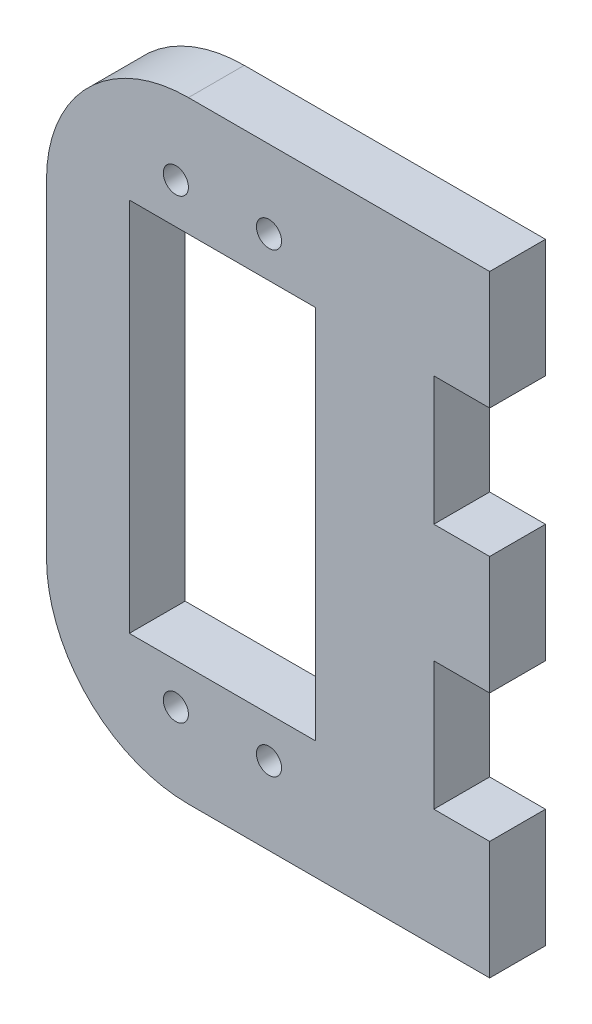
from build123d import *

# Parameters (mm, degrees)
SKETCH1_R           = 1.35
SKETCH1_W           = 20
SKETCH1_H           = 40.3
BOSS_EXTRUDE1_DEPTH = 5.9944


with BuildPart() as part:
    # Sketch1 → Boss-Extrude1 (new body)
    with BuildSketch(Plane.XY):
        with BuildLine():
            ThreePointArc((-18.89, 17.61), (-14.426307345, 28.386307345), (-3.65, 32.85))
            Line((-3.65, 32.85), (10, 32.85))
            Line((10, 32.85), (22.7, 32.85))
            Line((22.7, 32.85), (28.6944, 32.85))
            Line((28.6944, 32.85), (28.6944, 20.15))
            Line((28.6944, 20.15), (22.7, 20.15))
            Line((22.7, 20.15), (22.7, 6.35))
            Line((22.7, 6.35), (28.6944, 6.35))
            Line((28.6944, 6.35), (28.6944, 0))
            Line((28.6944, 0), (28.6944, -6.35))
            Line((28.6944, -6.35), (22.7, -6.35))
            Line((22.7, -6.35), (22.7, -20.15))
            Line((22.7, -20.15), (28.6944, -20.15))
            Line((28.6944, -20.15), (28.6944, -32.85))
            Line((28.6944, -32.85), (22.7, -32.85))
            Line((22.7, -32.85), (-3.65, -32.85))
            ThreePointArc((-3.65, -32.85), (-14.426307345, -28.386307345), (-18.89, -17.61))
            Line((-18.89, -17.61), (-18.89, 17.61))
        make_face()
        with Locations((5, 24.5)):
            Circle(SKETCH1_R, mode=Mode.SUBTRACT)
        with Locations((-5, 24.5)):
            Circle(SKETCH1_R, mode=Mode.SUBTRACT)
        with Locations((5, -24.5)):
            Circle(SKETCH1_R, mode=Mode.SUBTRACT)
        with Locations((-5, -24.5)):
            Circle(SKETCH1_R, mode=Mode.SUBTRACT)
        Rectangle(SKETCH1_W, SKETCH1_H, mode=Mode.SUBTRACT)
    extrude(amount=BOSS_EXTRUDE1_DEPTH)


solid = part.part
